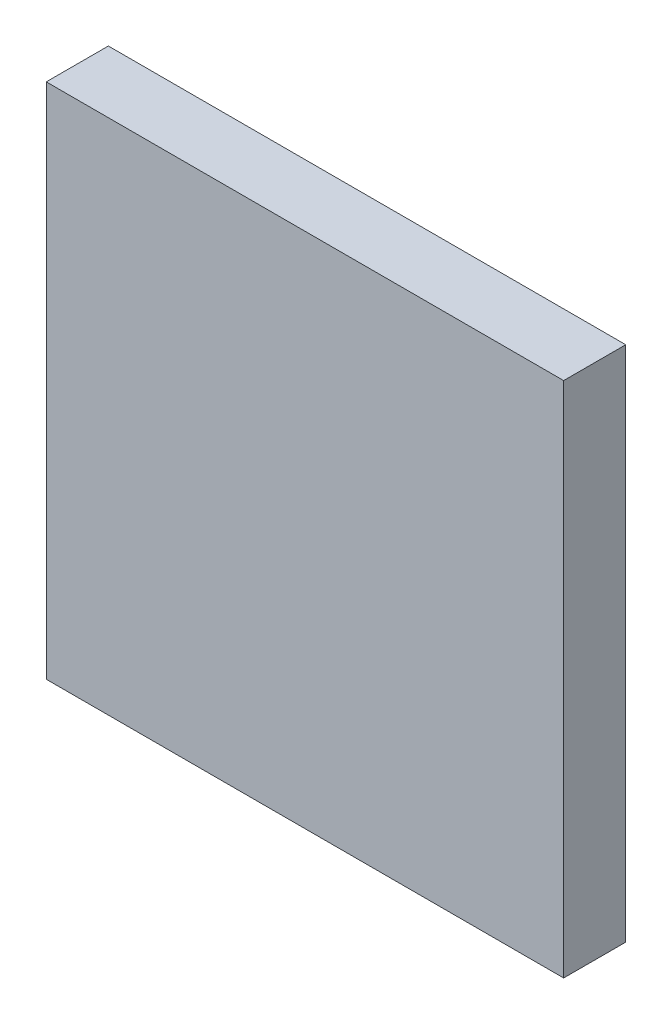
from build123d import *

# Parameters (mm, degrees)
SKETCH1_W           = 50
SKETCH1_H           = 50
BOSS_EXTRUDE1_DEPTH = 6


with BuildPart() as part:
    # Sketch1 → Boss-Extrude1 (new body)
    with BuildSketch(Plane.XY):
        with Locations((3.655660377, 4.068396226)):
            Rectangle(SKETCH1_W, SKETCH1_H)
    extrude(amount=BOSS_EXTRUDE1_DEPTH)


solid = part.part
